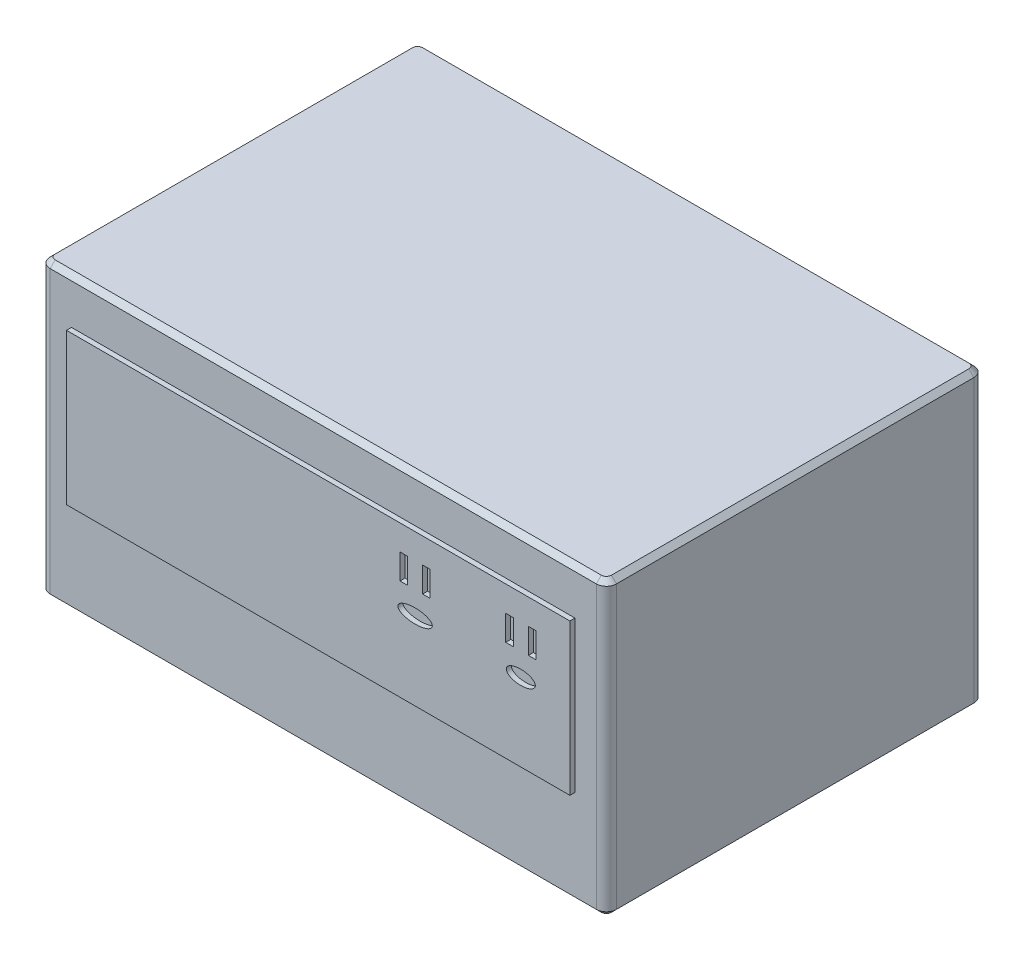
from build123d import *

# Parameters (mm, degrees)
SKETCH1_W           = 285.75
SKETCH1_H           = 190.5
BOSS_EXTRUDE1_DEPTH = 147.32
SKETCH2_W           = 254
SKETCH2_H           = 76.2
BOSS_EXTRUDE2_DEPTH = 2.54
SKETCH3_W           = 3.81
SKETCH3_H           = 12.7
SKETCH3_RX          = 8.66973746
SKETCH3_RY          = 3.553284778
SKETCH3_RX_2        = 7.32155449
CUT_EXTRUDE1_DEPTH  = 2.54
FILLET1_R           = 5.08
CHAMFER1_SIZE       = 2.54


with BuildPart() as part:
    # Sketch1 → Boss-Extrude1 (new body)
    with BuildSketch(Plane(origin=(0, 0, 0), x_dir=(1, 0, 0), z_dir=(0, 1, 0))):
        with Locations((0, -19.150408048)):
            Rectangle(SKETCH1_W, SKETCH1_H)
    extrude(amount=BOSS_EXTRUDE1_DEPTH)

    # Fillet1
    fillet1_edges = [part.edges().sort_by_distance(p)[0] for p in [
        (142.875, 73.66, 114.400408048),
        (-142.875, 73.66, 114.400408048),
        (-142.875, 73.66, -76.099591952),
        (142.875, 73.66, -76.099591952),
    ]]
    fillet(fillet1_edges, radius=FILLET1_R)

    # Chamfer1
    chamfer1_edges = [part.edges().sort_by_distance(p)[0] for p in [
        (-142.875, 0, 19.150408048),
        (-142.875, 147.32, 19.150408048),
        (142.875, 0, 19.150408048),
        (0, 0, 114.400408048),
        (0, 0, -76.099591952),
        (141.387102448, 0, 112.912510497),
        (141.387102448, 0, -74.6116944),
        (-141.387102448, 0, 112.912510497),
        (-141.387102448, 0, -74.6116944),
        (0, 147.32, -76.099591952),
        (142.875, 147.32, 19.150408048),
        (0, 147.32, 114.400408048),
        (141.387102448, 147.32, 112.912510497),
        (141.387102448, 147.32, -74.6116944),
        (-141.387102448, 147.32, 112.912510497),
        (-141.387102448, 147.32, -74.6116944),
    ]]
    chamfer(chamfer1_edges, length=CHAMFER1_SIZE)


with BuildPart() as body_2:
    # Sketch2 → Boss-Extrude2 (new body)
    with BuildSketch(Plane.XY.offset(114.400408048)):
        with Locations((0, 86.36)):
            Rectangle(SKETCH2_W, SKETCH2_H)
    extrude(amount=BOSS_EXTRUDE2_DEPTH)

    # Sketch3 → Cut-Extrude1 (cut)
    with BuildSketch(Plane.XY.offset(116.940408048)):
        with Locations((43.18, 105.41)):
            Rectangle(SKETCH3_W, SKETCH3_H)
        with Locations((54.61, 105.41)):
            Rectangle(SKETCH3_W, SKETCH3_H)
        with Locations(Location((48.895, 87.587623133), (0, 0, 0))):
            Ellipse(SKETCH3_RX, SKETCH3_RY)
        with Locations((102.235, 87.455169614)):
            Ellipse(SKETCH3_RX_2, SKETCH3_RY)
        with Locations((96.52, 105.27754648)):
            Rectangle(SKETCH3_W, SKETCH3_H)
        with Locations((107.95, 105.27754648)):
            Rectangle(SKETCH3_W, SKETCH3_H)
    extrude(amount=-CUT_EXTRUDE1_DEPTH, mode=Mode.SUBTRACT)


solid = Compound([part.part, body_2.part])
